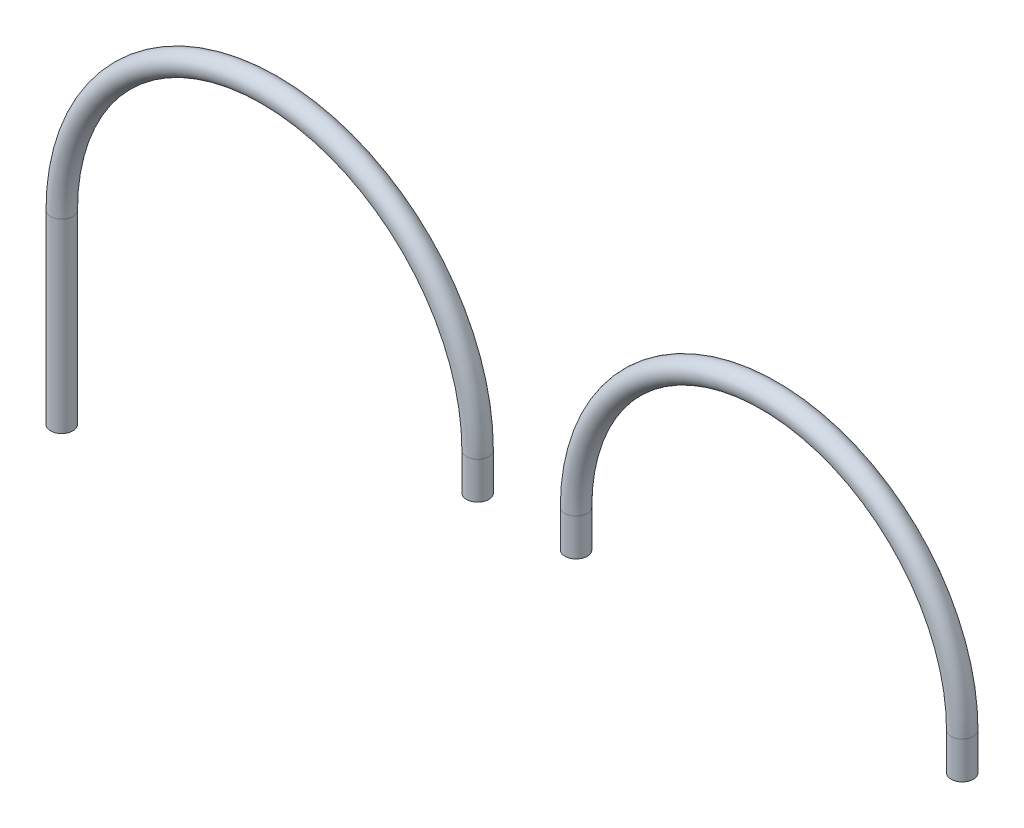
from build123d import *

# Parameters (mm, degrees)
SWEEP_THIN1_PROFILE_R   = 15
SWEEP_THIN1_PROFILE_R_2 = 14
SWEEP_THIN5_PROFILE_R   = 15
SWEEP_THIN5_PROFILE_R_2 = 14


with BuildPart() as part:
    # Sweep-Thin1: sweep along a path in Sketch1
    with BuildLine(Plane.XY) as sweep_thin1_path:
        Line((-1348.459533346, -250), (-1348.459533346, 0))
        ThreePointArc((-1348.459533346, 0), (-1068.459533346, 280), (-788.459533346, 0))
        Line((-788.459533346, 0), (-788.459533346, -50))
    # Sweep-Thin1 profile (on start of the path) → Sweep-Thin1 (sweep)
    with BuildSketch(Plane(origin=(-1348.459533346, -250, 0), x_dir=(1, 0, 0), z_dir=(0, 1, 0))):
        Circle(SWEEP_THIN1_PROFILE_R)
        Circle(SWEEP_THIN1_PROFILE_R_2, mode=Mode.SUBTRACT)
    sweep(path=sweep_thin1_path.line)


with BuildPart() as body_2:
    # Sweep-Thin5: sweep along a path in Sketch28
    with BuildLine(Plane.XY) as sweep_thin5_path:
        Line((-655.955136572, -50), (-655.955136572, 0))
        ThreePointArc((-655.955136572, 0), (-395.955136572, 260), (-135.955136572, 0))
        Line((-135.955136572, 0), (-135.955136572, -50))
    # Sweep-Thin5 profile (on start of the path) → Sweep-Thin5 (sweep)
    with BuildSketch(Plane(origin=(-655.955136572, -50, 0), x_dir=(0, 0, 1), z_dir=(0, 1, 0))):
        Circle(SWEEP_THIN5_PROFILE_R)
        Circle(SWEEP_THIN5_PROFILE_R_2, mode=Mode.SUBTRACT)
    sweep(path=sweep_thin5_path.line)


solid = Compound([part.part, body_2.part])
